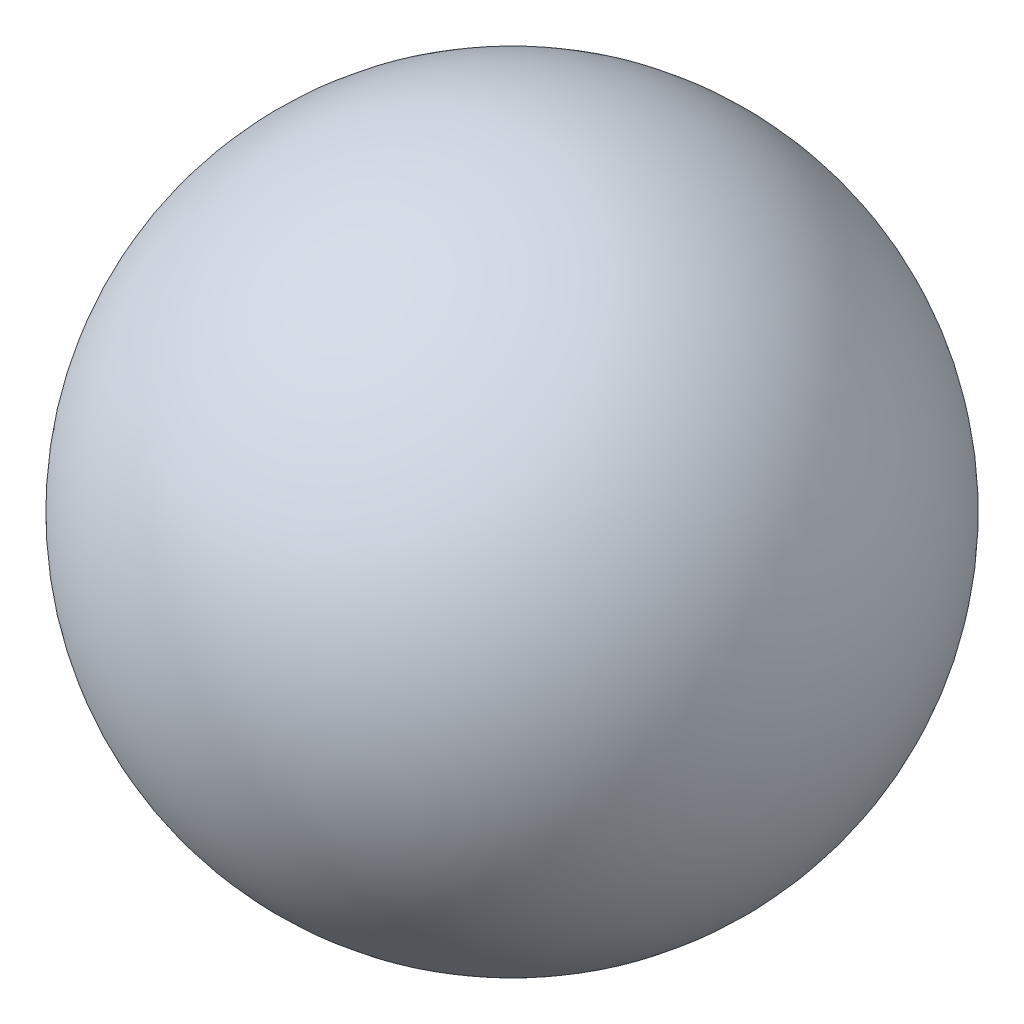
from build123d import *


with BuildPart() as part:
    # Sketch1 → Revolve2 (revolve)
    with BuildSketch(Plane.XY):
        with BuildLine():
            Line((0, 60.745166858), (0, -60.745166858))
            ThreePointArc((0, -60.745166858), (-60.745166858, 0), (0, 60.745166858))
        make_face()
    revolve(axis=Axis((0, 60.745166858, 0), (0, -1, 0)))


solid = part.part
